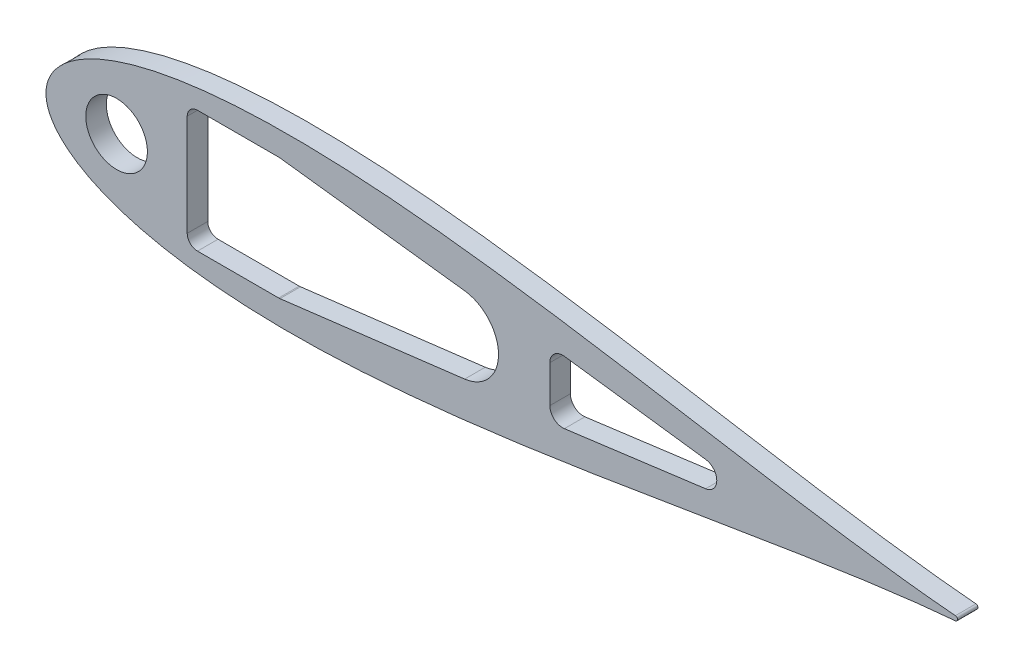
from build123d import *

# Parameters (mm, degrees)
BOSS_EXTRUDE1_DEPTH = 5.4737
SCALE1_SCALE        = 0.35
BOSS_EXTRUDE2_DEPTH = 5.08
SKETCH10_W          = 25.167167629
SKETCH10_H          = 30.1625
CUT_EXTRUDE6_DEPTH  = 6.0800001
FILLET1_R           = 2.54
CUT_EXTRUDE8_DEPTH  = 6.0800001
CUT_EXTRUDE9_DEPTH  = 6.0800001
SKETCH19_R          = 7.62
CUT_EXTRUDE10_DEPTH = 6.0800001


with BuildPart() as part:
    # Sketch2 → Boss-Extrude1 (new body)
    with BuildSketch(Plane.XY):
        with BuildLine():
            add(Edge.make_bspline(
                [(642.510849283, 1.582039112), (641.993392355, 1.625070631), (638.093728429, 1.953546407), (630.413817462, 2.663385493), (619.014124193, 3.849253664), (606.374988512, 5.304428983), (592.543922516, 7.037634907), (577.585454095, 9.050636147), (561.564270734, 11.338919625), (544.549749946, 13.890665375), (526.614143658, 16.687720753), (507.832591566, 19.705111663), (488.282710288, 22.911672601), (468.044367735, 26.27043606), (447.199424328, 29.739007432), (425.831595832, 33.270324121), (404.02631566, 36.813220545), (381.870662856, 40.313266856), (359.453314895, 43.713502532), (336.86454415, 46.955447457), (314.196207315, 49.979843895), (291.541767704, 52.727712704), (268.996310773, 55.141201012), (246.65655865, 57.164603829), (224.620860897, 58.745176641), (202.989192599, 59.8341217), (181.863132616, 60.387506142), (161.345829027, 60.366961324), (141.542033828, 59.739895824), (122.558104573, 58.481758104), (104.502313427, 56.574303932), (87.485018636, 54.008935199), (71.619696083, 50.784752003), (57.023709725, 46.912543066), (43.82045433, 42.41500246), (32.141645239, 37.332204029), (22.129107375, 31.731455339), (13.932423524, 25.726412106), (7.689616489, 19.513207632), (3.463136343, 13.420354421), (1.106333228, 7.923389435), (0.154611582, 3.513796615), (-0.062151598, 0), (0.154611582, -3.513796615), (1.106333228, -7.923389435), (3.463136343, -13.420354421), (7.689616489, -19.513207632), (13.932423524, -25.726412106), (22.129107375, -31.731455339), (32.141645239, -37.332204029), (43.82045433, -42.41500246), (57.023709725, -46.912543066), (71.619696083, -50.784752003), (87.485018636, -54.008935199), (104.502313427, -56.574303932), (122.558104573, -58.481758104), (141.542033828, -59.739895824), (161.345829027, -60.366961324), (181.863132616, -60.387506142), (202.989192599, -59.8341217), (224.620860897, -58.745176641), (246.65655865, -57.164603829), (268.996310773, -55.141201012), (291.541767704, -52.727712704), (314.196207315, -49.979843895), (336.86454415, -46.955447457), (359.453314895, -43.713502532), (381.870662856, -40.313266856), (404.02631566, -36.813220545), (425.831595832, -33.270324121), (447.199424328, -29.739007432), (468.044367735, -26.27043606), (488.282710288, -22.911672601), (507.832591566, -19.705111663), (526.614143658, -16.687720753), (544.549749946, -13.890665375), (561.564270734, -11.338919625), (577.585454095, -9.050636147), (592.543922516, -7.037634907), (606.374988512, -5.304428983), (619.014124193, -3.849253664), (630.413817462, -2.663385493), (638.093728429, -1.953546407), (641.993392355, -1.625070631), (642.510849283, -1.582039112)],
                knots=[0.020157042, 0.020157042, 0.020157042, 0.020157042, 0.021270888, 0.028552555, 0.036780684, 0.045920102, 0.055931764, 0.066772884, 0.07839713, 0.090754827, 0.103793165, 0.117456432, 0.131686226, 0.146421738, 0.161599998, 0.177156133, 0.193023668, 0.209134786, 0.225420633, 0.241811602, 0.258237647, 0.274628557, 0.290914287, 0.307025229, 0.322892517, 0.338448342, 0.353626207, 0.368361232, 0.382590428, 0.396252961, 0.409290412, 0.42164701, 0.433269881, 0.444109249, 0.45411864, 0.463255055, 0.471479114, 0.478755289, 0.485052318, 0.490344026, 0.494609833, 0.497833231, 0.5, 0.502166769, 0.505390167, 0.509655974, 0.514947682, 0.521244711, 0.528520886, 0.536744945, 0.54588136, 0.555890751, 0.566730119, 0.57835299, 0.590709588, 0.603747039, 0.617409572, 0.631638768, 0.646373793, 0.661551658, 0.677107483, 0.692974771, 0.709085713, 0.725371443, 0.741762353, 0.758188398, 0.774579367, 0.790865214, 0.806976332, 0.822843867, 0.838400002, 0.853578262, 0.868313774, 0.882543568, 0.896206835, 0.909245173, 0.92160287, 0.933227116, 0.944068236, 0.954079898, 0.963219316, 0.971447445, 0.978729112, 0.979842958, 0.979842958, 0.979842958, 0.979842958], degree=3))
            ThreePointArc((642.510849283, -1.582039112), (643.966787522, 0), (642.510849283, 1.582039112))
        make_face()
    extrude(amount=BOSS_EXTRUDE1_DEPTH)


with BuildPart() as part_1:
    # Scale1: scaled about (0, 0, 0)
    add(part.part.scale(SCALE1_SCALE))

    # Sketch11 → Boss-Extrude2 (add)
    with BuildSketch(Plane(origin=(0, 0, 0), x_dir=(-1, 0, 0), z_dir=(0, 0, -1))):
        with BuildLine():
            ThreePointArc((-224.878797249, 0.553713689), (-225.388375633, 0), (-224.878797249, -0.553713689))
            add(Edge.make_bspline(
                [(-224.878797249, -0.553713689), (-224.697687324, -0.568774721), (-223.33280495, -0.683741243), (-220.644836112, -0.932184923), (-216.654943468, -1.347238782), (-212.231245979, -1.856550144), (-207.390372881, -2.463172217), (-202.154908933, -3.167722651), (-196.547494757, -3.968621869), (-190.592412481, -4.861732881), (-184.31495028, -5.840702264), (-177.741407048, -6.896789082), (-170.898948601, -8.01908541), (-163.815528707, -9.194652621), (-156.519798515, -10.408652601), (-149.041058541, -11.644613442), (-141.409210481, -12.884627191), (-133.654731999, -14.1096434), (-125.808660213, -15.299725886), (-117.902590453, -16.43440661), (-109.96867256, -17.492945363), (-102.039618696, -18.454699446), (-94.148708771, -19.299420354), (-86.329795527, -20.00761134), (-78.617301314, -20.560811824), (-71.04621741, -20.941942595), (-63.652096416, -21.13562715), (-56.471040159, -21.128436463), (-49.53971184, -20.908963539), (-42.895336601, -20.468615336), (-36.5758097, -19.801006376), (-30.619756523, -18.90312732), (-25.066893629, -17.774663201), (-19.958298404, -16.419390073), (-15.337159016, -14.845250861), (-11.249575834, -13.06627141), (-7.745187581, -11.106009369), (-4.876348233, -9.004244237), (-2.691365771, -6.829622671), (-1.21209772, -4.697124047), (-0.38721663, -2.773186302), (-0.054114054, -1.229828815), (0.021753059, 0), (-0.054114054, 1.229828815), (-0.38721663, 2.773186302), (-1.21209772, 4.697124047), (-2.691365771, 6.829622671), (-4.876348233, 9.004244237), (-7.745187581, 11.106009369), (-11.249575834, 13.06627141), (-15.337159016, 14.845250861), (-19.958298404, 16.419390073), (-25.066893629, 17.774663201), (-30.619756523, 18.90312732), (-36.5758097, 19.801006376), (-42.895336601, 20.468615336), (-49.53971184, 20.908963539), (-56.471040159, 21.128436463), (-63.652096416, 21.13562715), (-71.04621741, 20.941942595), (-78.617301314, 20.560811824), (-86.329795527, 20.00761134), (-94.148708771, 19.299420354), (-102.039618696, 18.454699446), (-109.96867256, 17.492945363), (-117.902590453, 16.43440661), (-125.808660213, 15.299725886), (-133.654731999, 14.1096434), (-141.409210481, 12.884627191), (-149.041058541, 11.644613442), (-156.519798515, 10.408652601), (-163.815528707, 9.194652621), (-170.898948601, 8.01908541), (-177.741407048, 6.896789082), (-184.31495028, 5.840702264), (-190.592412481, 4.861732881), (-196.547494757, 3.968621869), (-202.154908933, 3.167722651), (-207.390372881, 2.463172217), (-212.231245979, 1.856550144), (-216.654943468, 1.347238782), (-220.644836112, 0.932184923), (-223.33280495, 0.683741243), (-224.697687324, 0.568774721), (-224.878797249, 0.553713689)],
                knots=[0.020157042, 0.020157042, 0.020157042, 0.020157042, 0.021270888, 0.028552555, 0.036780684, 0.045920102, 0.055931764, 0.066772884, 0.07839713, 0.090754827, 0.103793165, 0.117456432, 0.131686226, 0.146421738, 0.161599998, 0.177156133, 0.193023668, 0.209134786, 0.225420633, 0.241811602, 0.258237647, 0.274628557, 0.290914287, 0.307025229, 0.322892517, 0.338448342, 0.353626207, 0.368361232, 0.382590428, 0.396252961, 0.409290412, 0.42164701, 0.433269881, 0.444109249, 0.45411864, 0.463255055, 0.471479114, 0.478755289, 0.485052318, 0.490344026, 0.494609833, 0.497833231, 0.5, 0.502166769, 0.505390167, 0.509655974, 0.514947682, 0.521244711, 0.528520886, 0.536744945, 0.54588136, 0.555890751, 0.566730119, 0.57835299, 0.590709588, 0.603747039, 0.617409572, 0.631638768, 0.646373793, 0.661551658, 0.677107483, 0.692974771, 0.709085713, 0.725371443, 0.741762353, 0.758188398, 0.774579367, 0.790865214, 0.806976332, 0.822843867, 0.838400002, 0.853578262, 0.868313774, 0.882543568, 0.896206835, 0.909245173, 0.92160287, 0.933227116, 0.944068236, 0.954079898, 0.963219316, 0.971447445, 0.978729112, 0.979842958, 0.979842958, 0.979842958, 0.979842958], degree=3))
        make_face()
    extrude(amount=-BOSS_EXTRUDE2_DEPTH)

    # Sketch10 → Cut-Extrude6 (cut, through all)
    with BuildSketch(Plane.XY):
        with Locations((47.508583814, 0)):
            Rectangle(SKETCH10_W, SKETCH10_H)
    extrude(amount=CUT_EXTRUDE6_DEPTH, mode=Mode.SUBTRACT)

    # Fillet1
    fillet1_edges = [part_1.edges().sort_by_distance(p)[0] for p in [
        (60.092167629, -15.08125, 2.54),
        (60.092167629, 15.08125, 2.54),
        (34.925, 15.08125, 2.54),
        (34.925, -15.08125, 2.54),
    ]]
    fillet(fillet1_edges, radius=FILLET1_R)

    # Sketch16 → Cut-Extrude8 (cut, through all)
    with BuildSketch(Plane.XY.offset(5.08)):
        with BuildLine():
            Line((102.372583815, -9.525), (100.594583815, -9.525))
            ThreePointArc((100.594583815, -9.525), (91.069583815, 0), (100.594583815, 9.525))
            Line((100.594583815, 9.525), (102.372583815, 9.525))
            ThreePointArc((102.372583815, 9.525), (111.897583815, 0), (102.372583815, -9.525))
        make_face()
    extrude(amount=-CUT_EXTRUDE8_DEPTH, mode=Mode.SUBTRACT)

    # Sketch18 → Cut-Extrude9 (cut, through all)
    with BuildSketch(Plane.XY.offset(5.08)):
        with BuildLine():
            Line((57.861745058, 15.062313628), (103.533499174, 9.453988604))
            ThreePointArc((103.533499174, 9.453988604), (111.897583815, 0), (103.533499174, -9.453988604))
            Line((103.533499174, -9.453988604), (57.861745058, -15.062313628))
            ThreePointArc((57.861745058, -15.062313628), (59.454524939, -14.224293869), (60.092167629, -12.54125))
            Line((60.092167629, -12.54125), (60.092167629, 12.54125))
            ThreePointArc((60.092167629, 12.54125), (59.454524939, 14.224293869), (57.861745058, 15.062313628))
        make_face()
    extrude(amount=-CUT_EXTRUDE9_DEPTH, mode=Mode.SUBTRACT)

    # Sketch19 → Cut-Extrude10 (cut, through all)
    with BuildSketch(Plane.XY.offset(5.08)):
        with Locations((17.4625, 0)):
            Circle(SKETCH19_R)
        with BuildLine():
            Line((163.112004475, 3.147837435), (128.187004475, 7.745800913))
            ThreePointArc((128.187004475, 7.745800913), (125.679160852, 6.985054867), (124.597583815, 4.597963478))
            Line((124.597583815, 4.597963478), (124.597583815, -4.597963478))
            ThreePointArc((124.597583815, -4.597963478), (125.679160852, -6.985054867), (128.187004475, -7.745800913))
            Line((128.187004475, -7.745800913), (163.112004475, -3.147837435))
            ThreePointArc((163.112004475, -3.147837435), (165.872583815, 0), (163.112004475, 3.147837435))
        make_face()
    extrude(amount=-CUT_EXTRUDE10_DEPTH, mode=Mode.SUBTRACT)


solid = part_1.part
